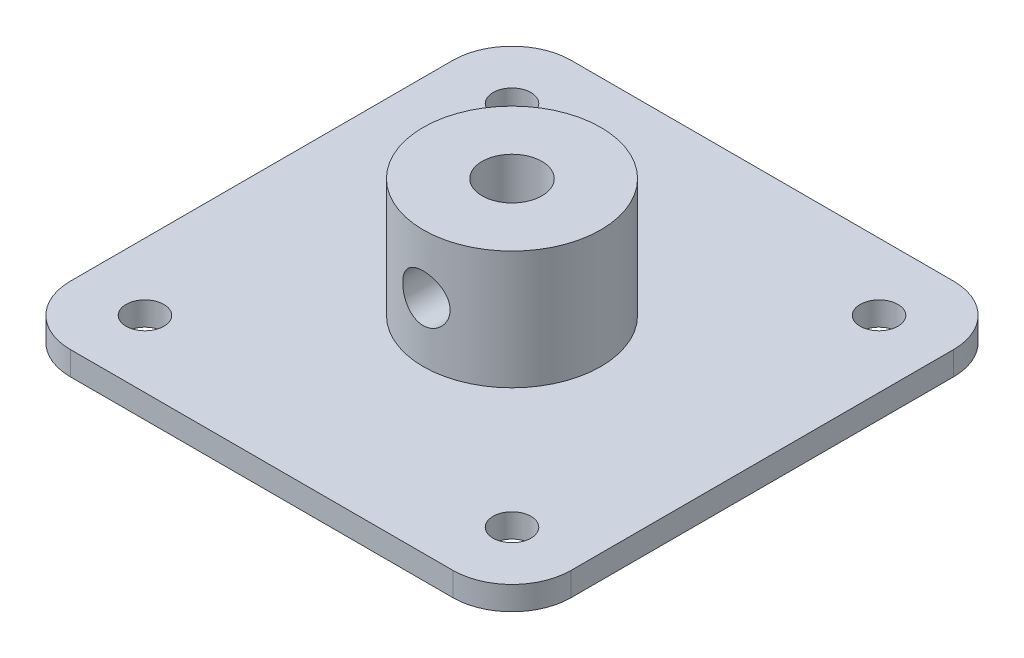
from build123d import *

# Parameters (mm, degrees)
SKETCH_1_W          = 42.3
SKETCH_1_H          = 42.3
EXTRUDE_1_DEPTH     = 2
SKETCH_2_R          = 1.6
CUT_EXTRUDE_1_DEPTH = 3
SKETCH_3_R          = 7.5
EXTRUDE_2_DEPTH     = 10
SKETCH_4_R          = 2.525
CUT_EXTRUDE_3_DEPTH = 13
FILLET_1_R          = 5
CUT_EXTRUDE_4_REACH = 30.65
SKETCH_5_R          = 2


with BuildPart() as part:
    # 草图1 → 凸台-拉伸1 (new body)
    with BuildSketch(Plane(origin=(0, 0, 0), x_dir=(1, 0, 0), z_dir=(0, 1, 0))):
        Rectangle(SKETCH_1_W, SKETCH_1_H)
    extrude(amount=EXTRUDE_1_DEPTH)

    # 草图2 → 切除-拉伸1 (cut, through all)
    with BuildSketch(Plane(origin=(0, 2, 0), x_dir=(1, 0, 0), z_dir=(0, 1, 0))):
        with Locations((-15.5, 15.5)):
            Circle(SKETCH_2_R)
        with Locations((15.5, 15.5)):
            Circle(SKETCH_2_R)
        with Locations((15.5, -15.5)):
            Circle(SKETCH_2_R)
        with Locations((-15.5, -15.5)):
            Circle(SKETCH_2_R)
    extrude(amount=-CUT_EXTRUDE_1_DEPTH, mode=Mode.SUBTRACT)

    # 草图3 → 凸台-拉伸2 (add)
    with BuildSketch(Plane(origin=(0, 2, 0), x_dir=(1, 0, 0), z_dir=(0, 1, 0))):
        Circle(SKETCH_3_R)
    extrude(amount=EXTRUDE_2_DEPTH)

    # 草图4 → 切除-拉伸3 (cut, through all)
    with BuildSketch(Plane(origin=(0, 12, 0), x_dir=(1, 0, 0), z_dir=(0, 1, 0))):
        Circle(SKETCH_4_R)
    extrude(amount=-CUT_EXTRUDE_3_DEPTH, mode=Mode.SUBTRACT)

    # 圆角1
    fillet_1_edges = [part.edges().sort_by_distance(p)[0] for p in [
        (21.15, 1, 21.15),
        (-21.15, 1, 21.15),
        (-21.15, 1, -21.15),
        (21.15, 1, -21.15),
    ]]
    fillet(fillet_1_edges, radius=FILLET_1_R)

    # 草图5 → 切除-拉伸4 (cut, up to next)
    with BuildSketch(Plane.XY.offset(7.5), mode=Mode.PRIVATE) as cut_extrude_4_sk1:
        with Locations((0, 7)):
            Circle(SKETCH_5_R)
    cut_extrude_4_tool1 = extrude(cut_extrude_4_sk1.sketch, amount=-CUT_EXTRUDE_4_REACH, mode=Mode.PRIVATE) & part.part
    add(cut_extrude_4_tool1.solids().sort_by_distance((0, 7, 7.5))[0], mode=Mode.SUBTRACT)


solid = part.part
